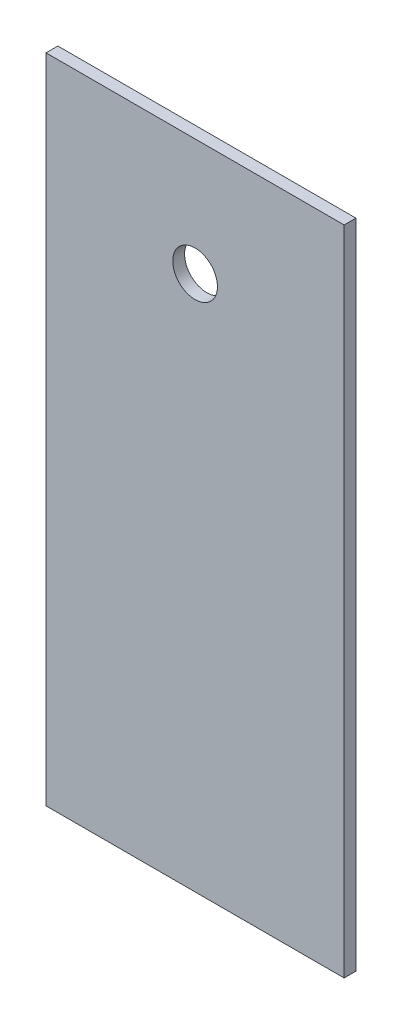
from build123d import *

# Parameters (mm, degrees)
SKETCH1_W                  = 80
SKETCH1_H                  = 175
BOSS_EXTRUDE1_DEPTH        = 3.175
F_12_0MM_DOWEL_HOLE1_D     = 12
F_12_0MM_DOWEL_HOLE1_DEPTH = 3.175


with BuildPart() as part:
    # Sketch1 → Boss-Extrude1 (new body)
    with BuildSketch(Plane.XY):
        Rectangle(SKETCH1_W, SKETCH1_H)
    extrude(amount=BOSS_EXTRUDE1_DEPTH)

    # Ø12.0mm Dowel Hole1
    with Locations(Plane.XY.offset(3.175)):
        with Locations((0, 56.15)):
            Hole(F_12_0MM_DOWEL_HOLE1_D / 2, depth=F_12_0MM_DOWEL_HOLE1_DEPTH)


solid = part.part
